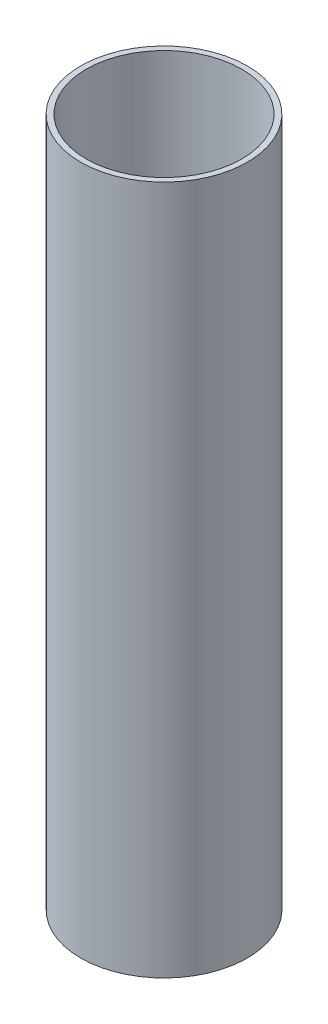
from build123d import *

# Parameters (mm, degrees)
SKETCH1_R           = 37.5
SKETCH1_R_2         = 35
BOSS_EXTRUDE1_DEPTH = 310


with BuildPart() as part:
    # Sketch1 → Boss-Extrude1 (new body)
    with BuildSketch(Plane(origin=(0, 0, 0), x_dir=(1, 0, 0), z_dir=(0, 1, 0))):
        Circle(SKETCH1_R)
        Circle(SKETCH1_R_2, mode=Mode.SUBTRACT)
    extrude(amount=BOSS_EXTRUDE1_DEPTH)


solid = part.part
